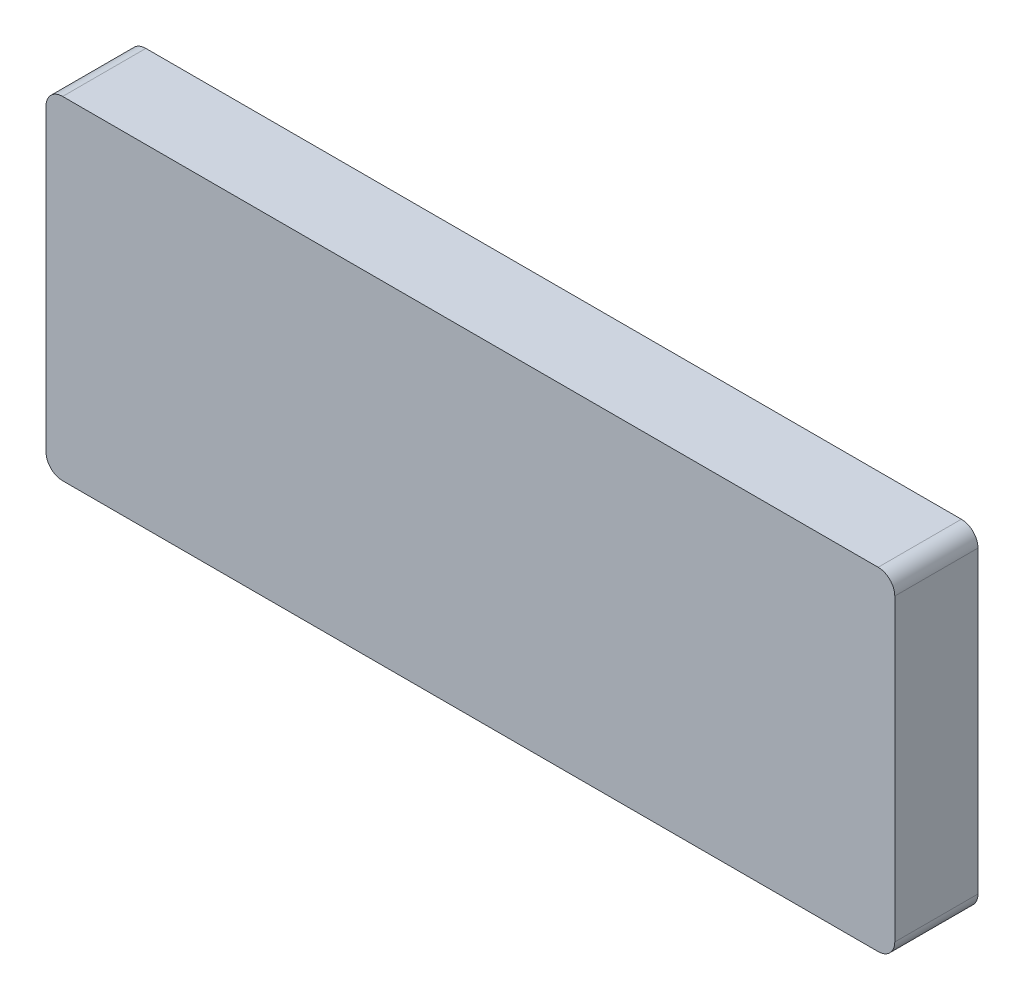
from build123d import *

# Parameters (mm, degrees)
BOSS_EXTRUDE1_DEPTH = 5


with BuildPart() as part:
    # Sketch3 → Boss-Extrude1 (new body)
    with BuildSketch(Plane.XY):
        with BuildLine():
            Line((-24, 10), (25, 10))
            ThreePointArc((25, 10), (25.707106781, 9.707106781), (26, 9))
            Line((26, 9), (26, -9))
            ThreePointArc((26, -9), (25.707106781, -9.707106781), (25, -10))
            Line((25, -10), (-24, -10))
            ThreePointArc((-24, -10), (-24.707106781, -9.707106781), (-25, -9))
            Line((-25, -9), (-25, 9))
            ThreePointArc((-25, 9), (-24.707106781, 9.707106781), (-24, 10))
        make_face()
    extrude(amount=BOSS_EXTRUDE1_DEPTH)


solid = part.part
